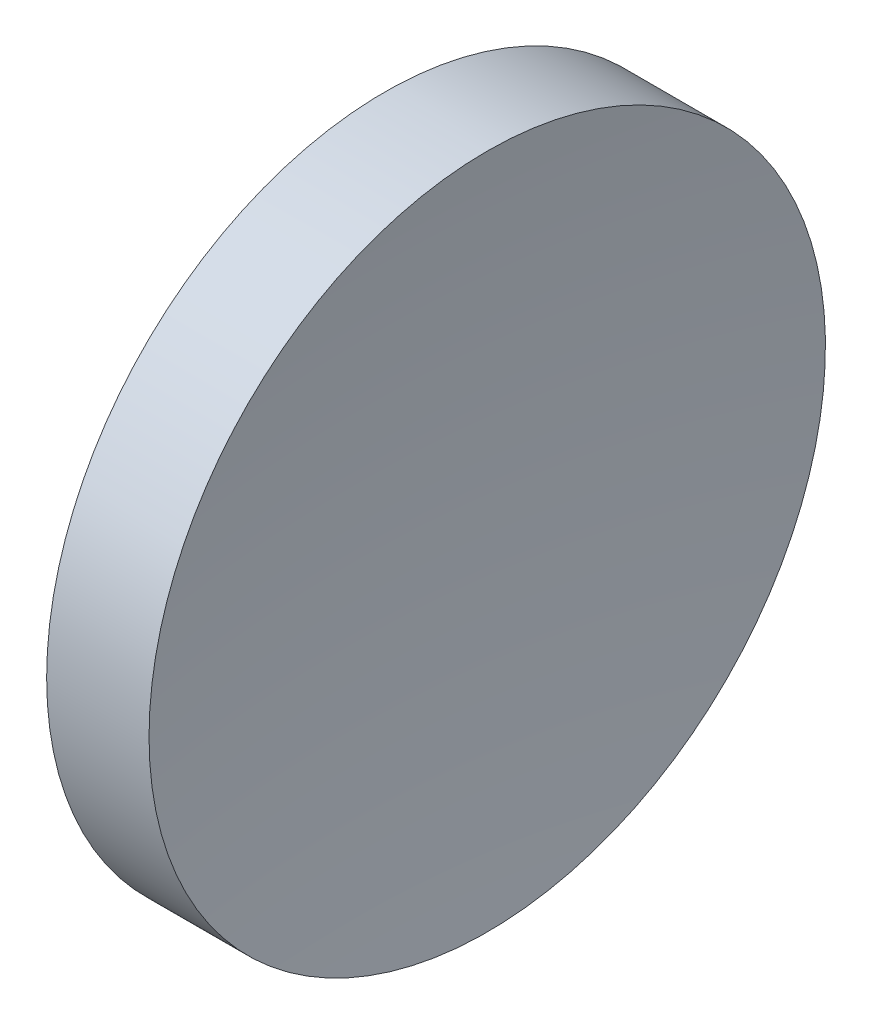
from build123d import *


with BuildPart() as part:
    # 草图1 → 旋转1 (revolve)
    with BuildSketch(Plane.XY):
        with BuildLine():
            Line((230.199611905, 138.756042247), (230.199611905, 176.256042247))
            Line((230.199611905, 176.256042247), (241.552589701, 176.256042247))
            ThreePointArc((241.552589701, 176.256042247), (239.788434425, 157.54291601), (239.199612196, 138.756042247))
            Line((239.199612196, 138.756042247), (230.199611905, 138.756042247))
        make_face()
    revolve(axis=Axis((217.970286004, 138.756042247, 0), (1, 0, 0)))


solid = part.part
